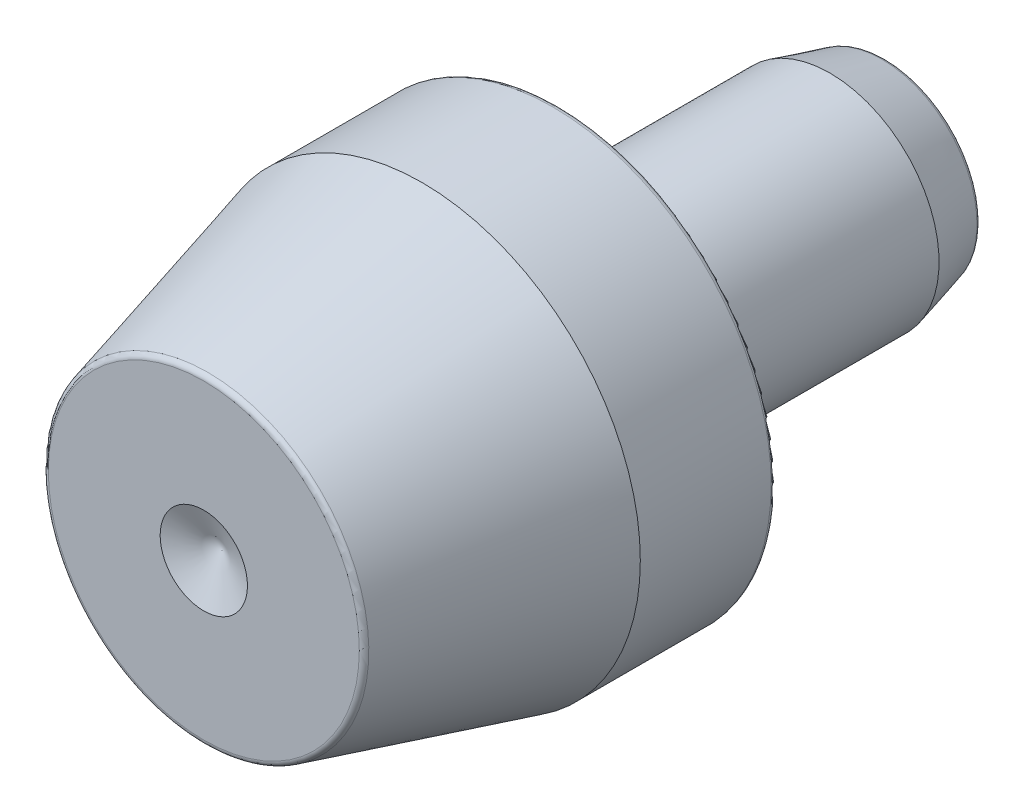
from build123d import *


with BuildPart() as part:
    # Sketch1 → Revolve1 (revolve)
    with BuildSketch(Plane(origin=(0, 0, 0), x_dir=(0, 0, -1), z_dir=(1, 0, 0))):
        with BuildLine():
            Line((-12.5, 1.6), (-12.5, 5.699104428))
            ThreePointArc((-12.5, 5.699104428), (-12.457637435, 5.823900521), (-12.348057904, 5.897119222))
            Line((-12.348057904, 5.897119222), (-4.5, 8))
            Line((-4.5, 8), (0.295, 8))
            ThreePointArc((0.295, 8), (0.43995689, 7.93995689), (0.5, 7.795))
            Line((0.5, 7.795), (0.5, 4.615))
            ThreePointArc((0.5, 4.615), (0.35504311, 4.55495689), (0.295, 4.41))
            Line((0.295, 4.41), (0.295, 4))
            ThreePointArc((0.295, 4), (0.35504311, 3.85504311), (0.5, 3.795))
            Line((0.5, 3.795), (1.525, 3.795))
            Line((1.525, 3.795), (1.73, 4))
            Line((1.73, 4), (10.45, 4))
            Line((10.45, 4), (12.348057904, 3.491416917))
            ThreePointArc((12.348057904, 3.491416917), (12.457637435, 3.418198216), (12.5, 3.293402123))
            Line((12.5, 3.293402123), (12.5, 0))
            Line((12.5, 0), (-11.8372583, 0))
            Line((-11.8372583, 0), (-12.5, 1.6))
        make_face()
    revolve(axis=Axis((0, 0, -12.5), (0, 0, 1)))


solid = part.part
